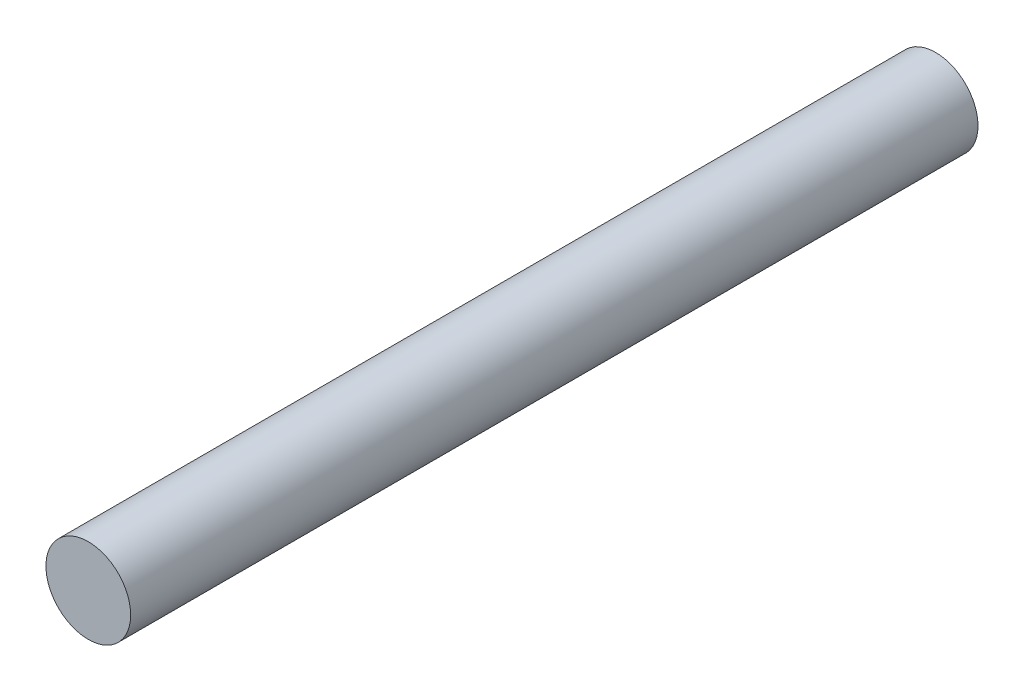
from build123d import *

# Parameters (mm, degrees)
BOSS_EXTRUDE1_DEPTH      = 30
BOSS_EXTRUDE1_DEPTH_BACK = 30
SKETCH1_R                = 3


with BuildPart() as part:
    # Sketch1 → Boss-Extrude1 (new, two sides: drawn at the far end of the back side and taken through both)
    with BuildSketch(Plane.XY.offset(-BOSS_EXTRUDE1_DEPTH_BACK)):
        Circle(SKETCH1_R)
    extrude(amount=BOSS_EXTRUDE1_DEPTH + BOSS_EXTRUDE1_DEPTH_BACK)


solid = part.part
